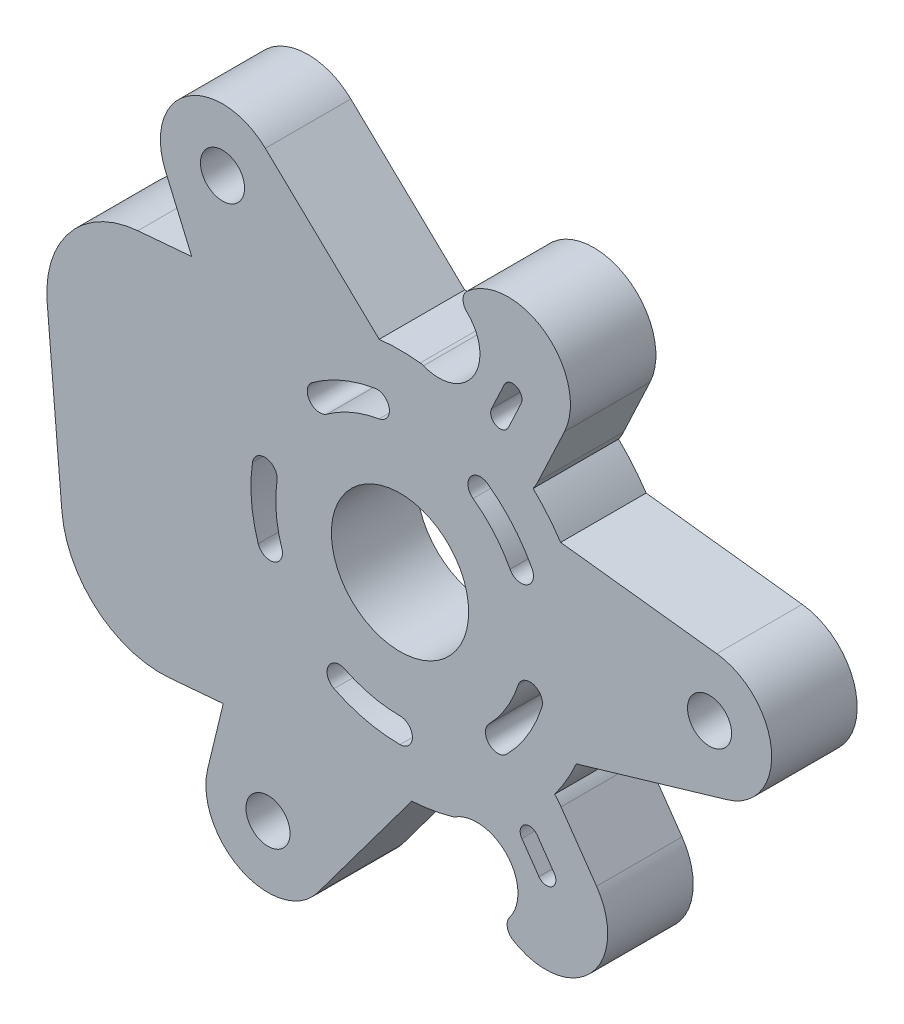
from build123d import *

# Parameters (mm, degrees)
SKETCH1_R           = 30
BOSS_EXTRUDE1_DEPTH = 6.88
SKETCH2_R           = 1.775
CUT_EXTRUDE1_DEPTH  = 7.88
SKETCH3_R           = 5.525
CUT_EXTRUDE2_DEPTH  = 7.88
SKETCH4_R           = 15.5
SKETCH4_R_2         = 5.525
BOSS_EXTRUDE2_DEPTH = 6.88
BOSS_EXTRUDE3_DEPTH = 6.88
FILLET1_R           = 8
BOSS_EXTRUDE4_DEPTH = 6.88
SKETCH8_R           = 3.307099625
CUT_EXTRUDE3_DEPTH  = 7.88
FILLET2_R           = 1
CUT_EXTRUDE4_DEPTH  = 7.8800001
CIRPATTERN7_COUNT   = 5


with BuildPart() as part:
    # Sketch1 → Boss-Extrude1 (new body)
    with BuildSketch(Plane.XY):
        Circle(SKETCH1_R)
    extrude(amount=BOSS_EXTRUDE1_DEPTH)

    # Sketch2 → Cut-Extrude1 (cut, through all)
    with BuildSketch(Plane.XY.offset(6.88)):
        with BuildLine():
            ThreePointArc((-12.74957851, -27.155998376), (-15.133105802, -24.791899388), (-15.484190638, -21.453201167))
            Line((-15.484190638, -21.453201167), (-10.504897898, -0.891395226))
            Line((-10.504897898, -0.891395226), (-18.877603208, 18.537424231))
            ThreePointArc((-18.877603208, 18.537424231), (-19.094099282, 21.887543025), (-17.142995258, 24.619458028))
            ThreePointArc((-17.142995258, 24.619458028), (-29.892573711, -2.536540344), (-12.74957851, -27.155998376))
        make_face()
        with BuildLine():
            ThreePointArc((29.89257372, 2.536540246), (12.74957851, 27.155998377), (-17.142995258, 24.619458028))
            ThreePointArc((-17.142995258, 24.619458028), (-13.90386181, 25.50160376), (-10.836921884, 24.136303033))
            Line((-10.836921884, 24.136303033), (4.480478038, 9.543206057))
            Line((4.480478038, 9.543206057), (25.492681909, 7.079771826))
            ThreePointArc((25.492681909, 7.079771826), (28.502217973, 5.59220348), (29.89257372, 2.536540246))
        make_face()
        with BuildLine():
            ThreePointArc((-6.6150787, -25.617196056), (-9.408118678, -27.479746561), (-12.74957851, -27.155998376))
            ThreePointArc((-12.74957851, -27.155998376), (16.085904462, -25.322789689), (30, 0))
            ThreePointArc((30, 0), (29.973131398, 1.269407029), (29.89257372, 2.536540246))
            ThreePointArc((29.89257372, 2.536540246), (29.905999993, 2.325351424), (29.910478091, 2.113783634))
            ThreePointArc((29.910478091, 2.113783634), (28.913799972, -0.881782076), (26.321112522, -2.683101866))
            Line((26.321112522, -2.683101866), (6.02441986, -8.65181083))
            Line((6.02441986, -8.65181083), (-6.6150787, -25.617196056))
        make_face()
        with Locations((-10.62464872, -22.629998665)):
            Circle(SKETCH2_R)
        with Locations((24.910478091, 2.113783634)):
            Circle(SKETCH2_R)
        with Locations((-14.285829371, 20.51621503)):
            Circle(SKETCH2_R)
    extrude(amount=-CUT_EXTRUDE1_DEPTH, mode=Mode.SUBTRACT)

    # Sketch3 → Cut-Extrude2 (cut, through all)
    with BuildSketch(Plane.XY.offset(6.88)):
        Circle(SKETCH3_R)
    extrude(amount=-CUT_EXTRUDE2_DEPTH, mode=Mode.SUBTRACT)

    # Sketch4 → Boss-Extrude2 (add)
    with BuildSketch(Plane.XY.offset(6.88)):
        Circle(SKETCH4_R)
        Circle(SKETCH4_R_2, mode=Mode.SUBTRACT)
    extrude(amount=-BOSS_EXTRUDE2_DEPTH)

    # Sketch6 → Boss-Extrude3 (add)
    with BuildSketch(Plane.XY.offset(6.88)):
        with BuildLine():
            Line((-5.159411249, 14.616103296), (-29.073470217, 12.586871007))
            Line((-29.073470217, 12.586871007), (-26.536929856, -17.305702703))
            Line((-26.536929856, -17.305702703), (-2.622870888, -15.276470414))
            ThreePointArc((-2.622870888, -15.276470414), (-15.444496417, -1.310545853), (-5.159411249, 14.616103296))
        make_face()
    extrude(amount=-BOSS_EXTRUDE3_DEPTH)

    # Fillet1
    fillet1_edges = [part.edges().sort_by_distance(p)[0] for p in [
        (-26.536929856, -17.305702703, 3.44),
        (-29.073470217, 12.586871007, 3.44),
    ]]
    fillet(fillet1_edges, radius=FILLET1_R)

    # Sketch7 → Boss-Extrude4 (add)
    with BuildSketch(Plane.XY.offset(6.88)):
        with BuildLine():
            Line((13.238211684, 16.431669161), (11.11328194, 11.905669428))
            ThreePointArc((11.11328194, 11.905669428), (4.462352462, 9.504599439), (2.061282474, 16.155528916))
            Line((2.061282474, 16.155528916), (4.186212218, 20.681528649))
            ThreePointArc((4.186212218, 20.681528649), (10.837141695, 23.082598638), (13.238211684, 16.431669161))
        make_face()
        with BuildLine():
            Line((15.817623091, -13.966130451), (12.960457216, -9.862887445))
            ThreePointArc((12.960457216, -9.862887445), (6.000048336, -8.616810313), (4.753971204, -15.577219193))
            Line((4.753971204, -15.577219193), (7.611137078, -19.680462199))
            ThreePointArc((7.611137078, -19.680462199), (14.571545959, -20.926539331), (15.817623091, -13.966130451))
        make_face()
    extrude(amount=-BOSS_EXTRUDE4_DEPTH)

    # Sketch8 → Cut-Extrude3 (cut, through all)
    with BuildSketch(Plane.XY.offset(6.88)):
        with Locations((6.182554141, -17.628840696)):
            Circle(SKETCH8_R)
        with Locations((3.123747346, 18.418528783)):
            Circle(SKETCH8_R)
        with BuildLine():
            Line((11.036190469, -12.786856964), (12.40767393, -14.756476568))
            ThreePointArc((12.40767393, -14.756476568), (12.22076236, -15.8005379), (11.176701028, -15.61362633))
            Line((11.176701028, -15.61362633), (9.805217567, -13.644006726))
            ThreePointArc((9.805217567, -13.644006726), (9.992129137, -12.599945394), (11.036190469, -12.786856964))
        make_face()
        with BuildLine():
            Line((8.723847544, 14.463598968), (9.743846426, 16.636148288))
            ThreePointArc((9.743846426, 16.636148288), (9.383685928, 17.63378771), (8.386046507, 17.273627211))
            Line((8.386046507, 17.273627211), (7.366047624, 15.101077892))
            ThreePointArc((7.366047624, 15.101077892), (7.726208122, 14.10343847), (8.723847544, 14.463598968))
        make_face()
    extrude(amount=-CUT_EXTRUDE3_DEPTH, mode=Mode.SUBTRACT)

    # Fillet2
    fillet2_edges = [part.edges().sort_by_distance(p)[0] for p in [
        (1.777810772, 15.39770726, 3.44),
        (4.346861748, -14.87799694, 3.44),
        (4.588201724, 21.383706907, 3.44),
        (8.125694034, -20.304866722, 3.44),
    ]]
    fillet(fillet2_edges, radius=FILLET2_R)

    # Sketch10 → Cut-Extrude4 (cut, through all)
    with BuildSketch(Plane.XY.offset(6.88)):
        with BuildLine():
            ThreePointArc((-11.874722343, 1.729441895), (-11.957029484, -1.014616145), (-11.413533187, -3.705571507))
            ThreePointArc((-11.413533187, -3.705571507), (-10.153607796, -4.347901647), (-9.511277656, -3.087976256))
            ThreePointArc((-9.511277656, -3.087976256), (-9.964191237, -0.845513454), (-9.895601953, 1.441201579))
            ThreePointArc((-9.895601953, 1.441201579), (-10.74104199, 2.574881932), (-11.874722343, 1.729441895))
        make_face()
    cut_extrude4 = extrude(amount=-CUT_EXTRUDE4_DEPTH, mode=Mode.SUBTRACT)

    # CirPattern7: Cut-Extrude4 ×5 about axis
    cirpattern7_axis = Axis((0, 0, 0), (0, 0, 1))
    for i in range(1, CIRPATTERN7_COUNT):
        add(cut_extrude4.rotate(cirpattern7_axis, i * 360 / CIRPATTERN7_COUNT), mode=Mode.SUBTRACT)


solid = part.part
